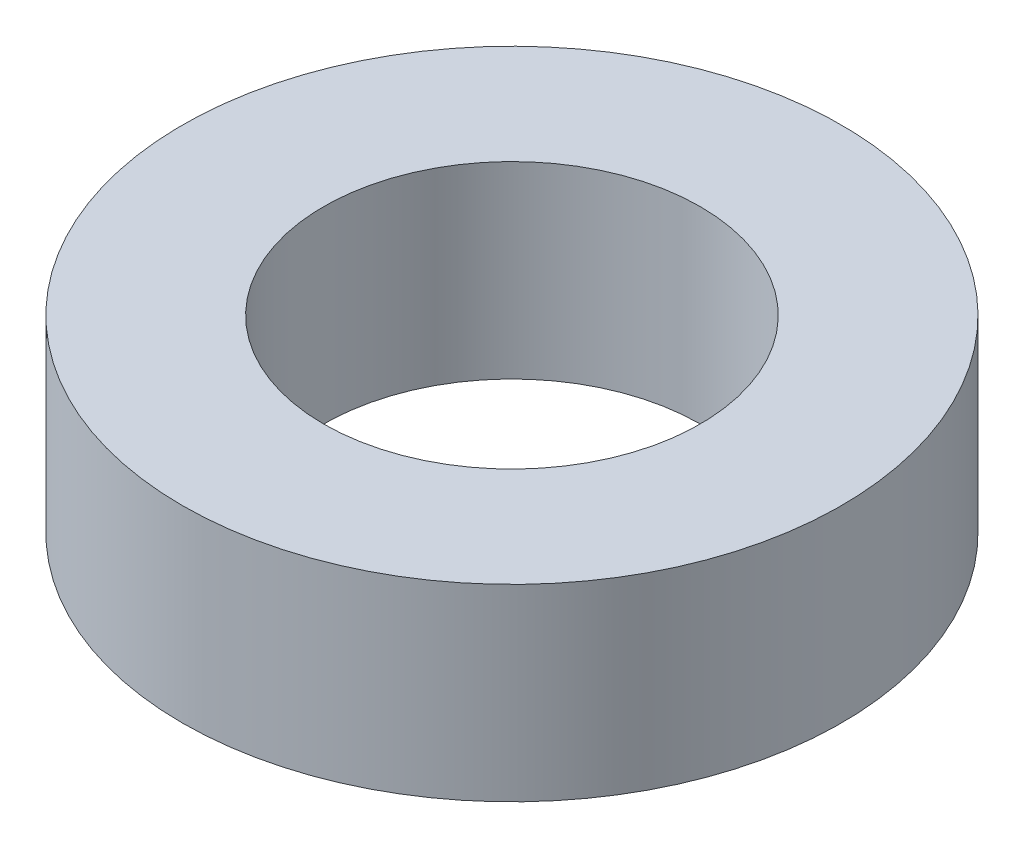
from build123d import *

# Parameters (mm, degrees)
SKETCH_1_R      = 3.5
SKETCH_1_R_2    = 2
EXTRUDE_1_DEPTH = 2


with BuildPart() as part:
    # 스케치1 → 보스-돌출1 (new body)
    with BuildSketch(Plane(origin=(0, 0, 0), x_dir=(1, 0, 0), z_dir=(0, 1, 0))):
        Circle(SKETCH_1_R)
        Circle(SKETCH_1_R_2, mode=Mode.SUBTRACT)
    extrude(amount=EXTRUDE_1_DEPTH)


solid = part.part
